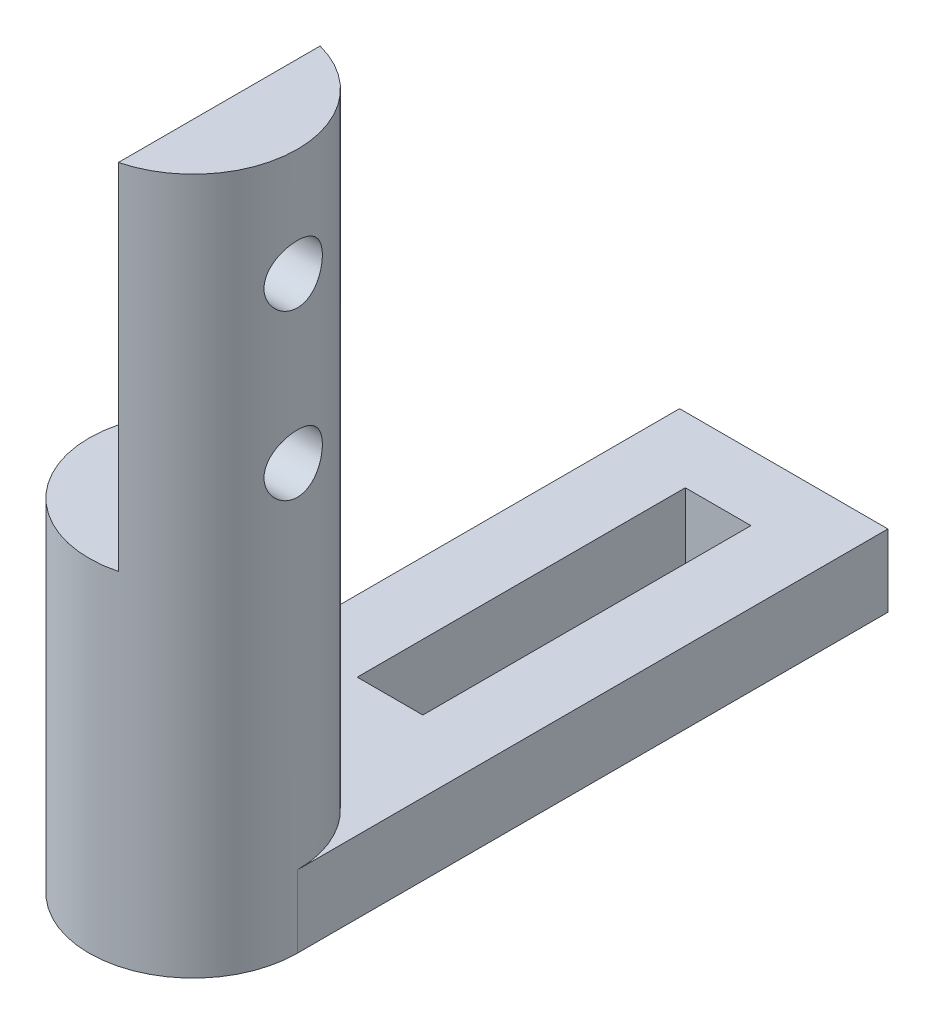
from build123d import *

# Parameters (mm, degrees)
SKETCH_1_R          = 3.175
EXTRUDE_1_DEPTH     = 57.15
CUT_EXTRUDE_1_DEPTH = 10.795
SKETCH_3_R          = 0.889
CUT_EXTRUDE_2_DEPTH = 10.795
SKETCH_4_R          = 3.175
CUT_EXTRUDE_3_DEPTH = 37.03
SKETCH_5_W          = 2
SKETCH_5_H          = 10
EXTRUDE_2_DEPTH     = 1.1


with BuildPart() as part:
    # 草图1 → 凸台-拉伸1 (new body)
    with BuildSketch(Plane(origin=(0, 0, 0), x_dir=(1, 0, 0), z_dir=(0, 1, 0))):
        Circle(SKETCH_1_R)
    extrude(amount=EXTRUDE_1_DEPTH)

    # 草图2 → 切除-拉伸1 (cut)
    with BuildSketch(Plane(origin=(0, 57.15, 0), x_dir=(1, 0, 0), z_dir=(0, 1, 0))):
        Polygon((-0.794, 3.175), (0.794, 3.175), (0.794, -3.175), (-3.175, -3.175), (-3.175, 3.175), align=None)
    extrude(amount=-CUT_EXTRUDE_1_DEPTH, mode=Mode.SUBTRACT)

    # 草图3 → 切除-拉伸2 (cut)
    with BuildSketch(Plane.ZY.offset(-0.794)):
        with Locations((0, 53.855)):
            Circle(SKETCH_3_R)
        with Locations((0, 48.855)):
            Circle(SKETCH_3_R)
    extrude(amount=-CUT_EXTRUDE_2_DEPTH, mode=Mode.SUBTRACT)

    # 草图4 → 切除-拉伸3 (cut)
    with BuildSketch(Plane.XZ):
        Circle(SKETCH_4_R)
    extrude(amount=-CUT_EXTRUDE_3_DEPTH, mode=Mode.SUBTRACT)

    # 草图5 → 凸台-拉伸2 (add, symmetric)
    with BuildSketch(Plane.XZ.offset(-37.03)):
        with BuildLine():
            Line((3.175, 0), (3.175, -18))
            Line((3.175, -18), (-3.175, -18))
            Line((-3.175, -18), (-3.175, 0))
            ThreePointArc((-3.175, 0), (0, 3.175), (3.175, 0))
        make_face()
        with Locations((0, -11)):
            Rectangle(SKETCH_5_W, SKETCH_5_H, mode=Mode.SUBTRACT)
    extrude(amount=EXTRUDE_2_DEPTH, both=True)


solid = part.part
